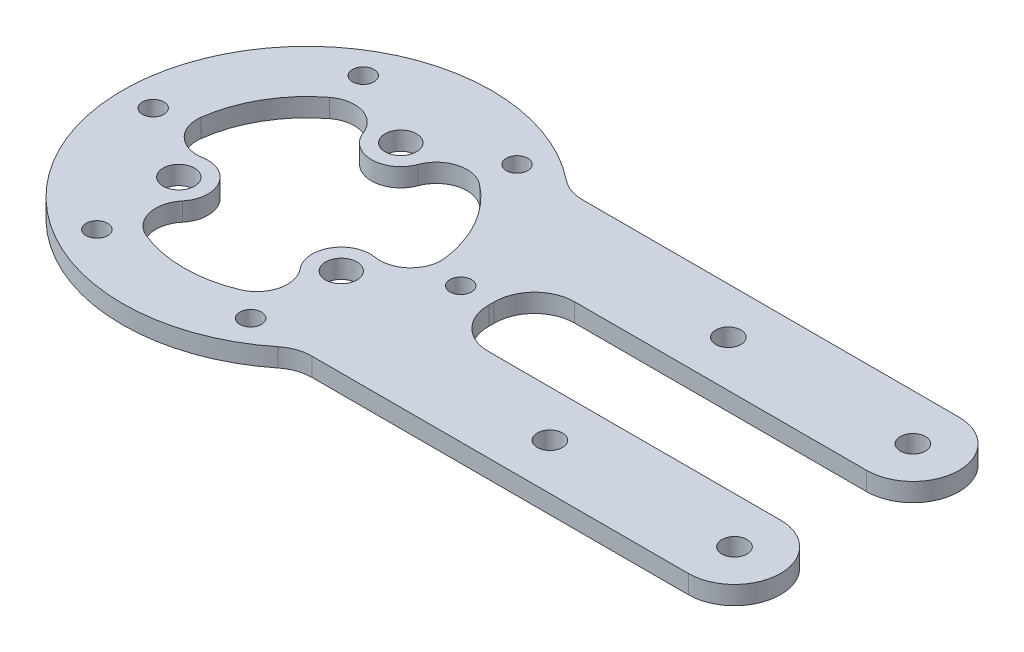
from build123d import *

# Parameters (mm, degrees)
SKETCH1_R           = 30
SKETCH1_R_2         = 20
BOSS_EXTRUDE1_DEPTH = 3
SKETCH2_R           = 2.55
BOSS_EXTRUDE2_DEPTH = 3
CIRPATTERN1_COUNT   = 3
BOSS_EXTRUDE3_DEPTH = 3
SKETCH4_R           = 2.05
CUT_EXTRUDE1_DEPTH  = 104.489129864
SKETCH6_R           = 1.75
CUT_EXTRUDE2_DEPTH  = 104.489129864
CIRPATTERN2_COUNT   = 6
CUT_EXTRUDE3_DEPTH  = 104.489129864
FILLET1_R           = 5
FILLET2_R           = 6.5


with BuildPart() as part:
    # Sketch1 → Boss-Extrude1 (new body)
    with BuildSketch(Plane(origin=(0, 0, 0), x_dir=(1, 0, 0), z_dir=(0, 1, 0))):
        with Locations(Location((0, 0, 0), (0, 0, 270))):
            Circle(SKETCH1_R)
        with Locations(Location((0, 0, 0), (0, 0, 270))):
            Circle(SKETCH1_R_2, mode=Mode.SUBTRACT)
    extrude(amount=BOSS_EXTRUDE1_DEPTH)

    # Sketch2 → Boss-Extrude2 (add)
    with BuildSketch(Plane(origin=(0, 3, 0), x_dir=(1, 0, 0), z_dir=(0, 1, 0))):
        with BuildLine():
            Line((-4.75, 15.25), (-4.75, 19.42775077))
            ThreePointArc((-4.75, 19.42775077), (0, 20), (4.75, 19.42775077))
            Line((4.75, 19.42775077), (4.75, 15.25))
            ThreePointArc((4.75, 15.25), (0, 10.5), (-4.75, 15.25))
        make_face()
        with Locations(Location((0, 15.25, 0), (0, 0, 270))):
            Circle(SKETCH2_R, mode=Mode.SUBTRACT)
    boss_extrude2 = extrude(amount=-BOSS_EXTRUDE2_DEPTH)

    # CirPattern1: Boss-Extrude2 ×3 about axis
    cirpattern1_axis = Axis((0, 0, 0), (0, 1, 0))
    for i in range(1, CIRPATTERN1_COUNT):
        add(boss_extrude2.rotate(cirpattern1_axis, i * 360 / CIRPATTERN1_COUNT))

    # Sketch3 → Boss-Extrude3 (add)
    with BuildSketch(Plane(origin=(0, 3, 0), x_dir=(1, 0, 0), z_dir=(0, 1, 0))):
        with BuildLine():
            Line((20.396078054, 22), (99, 22))
            Line((99, 22), (99, 7))
            Line((99, 7), (29.171904292, 7))
            ThreePointArc((29.171904292, 7), (25.893941733, 15.149382216), (20.396078054, 22))
        make_face()
        with BuildLine():
            Line((29.171904292, -7), (99, -7))
            Line((99, -7), (99, -22))
            Line((99, -22), (20.396078054, -22))
            ThreePointArc((20.396078054, -22), (25.893941733, -15.149382216), (29.171904292, -7))
        make_face()
    extrude(amount=-BOSS_EXTRUDE3_DEPTH)

    # Sketch4 → Cut-Extrude1 (cut, through all)
    with BuildSketch(Plane(origin=(0, 3, 0), x_dir=(1, 0, 0), z_dir=(0, 1, 0))):
        with Locations(Location((54, 14.5, 0), (0, 0, 270))):
            Circle(SKETCH4_R)
        with Locations(Location((84, 14.5, 0), (0, 0, 270))):
            Circle(SKETCH4_R)
        with Locations(Location((54, -14.5, 0), (0, 0, 270))):
            Circle(SKETCH4_R)
        with Locations(Location((84, -14.5, 0), (0, 0, 270))):
            Circle(SKETCH4_R)
    extrude(amount=-CUT_EXTRUDE1_DEPTH, mode=Mode.SUBTRACT)

    # Sketch6 → Cut-Extrude2 (cut, through all)
    with BuildSketch(Plane.XZ):
        with Locations(Location((25, 0, 0), (0, 0, 270))):
            Circle(SKETCH6_R)
    cut_extrude2 = extrude(amount=-CUT_EXTRUDE2_DEPTH, mode=Mode.SUBTRACT)

    # CirPattern2: Cut-Extrude2 ×6 about axis
    cirpattern2_axis = Axis((0, 0, 0), (0, 1, 0))
    for i in range(1, CIRPATTERN2_COUNT):
        add(cut_extrude2.rotate(cirpattern2_axis, i * 360 / CIRPATTERN2_COUNT), mode=Mode.SUBTRACT)

    # Sketch7 → Cut-Extrude3 (cut, through all)
    with BuildSketch(Plane.XZ):
        with BuildLine():
            Line((99, 22), (84, 22))
            ThreePointArc((84, 22), (91.5, 14.5), (84, 7))
            Line((84, 7), (99, 7))
            Line((99, 7), (99, 22))
        make_face()
        with BuildLine():
            Line((99, -7), (84, -7))
            ThreePointArc((84, -7), (91.5, -14.5), (84, -22))
            Line((84, -22), (99, -22))
            Line((99, -22), (99, -7))
        make_face()
    extrude(amount=-CUT_EXTRUDE3_DEPTH, mode=Mode.SUBTRACT)

    # Fillet1
    fillet1_edges = [part.edges().sort_by_distance(p)[0] for p in [
        (19.199925706, 1.5, 5.600254717),
        (14.449925706, 1.5, 13.827496053),
        (-19.199925706, 1.5, 5.600254717),
        (-14.449925706, 1.5, 13.827496053),
        (4.75, 1.5, -19.42775077),
        (-4.75, 1.5, -19.42775077),
    ]]
    fillet(fillet1_edges, radius=FILLET1_R)

    # Fillet2
    fillet2_edges = [part.edges().sort_by_distance(p)[0] for p in [
        (29.171904292, 1.5, -7),
        (20.396078054, 1.5, -22),
        (20.396078054, 1.5, 22),
        (29.171904292, 1.5, 7),
    ]]
    fillet(fillet2_edges, radius=FILLET2_R)


solid = part.part
